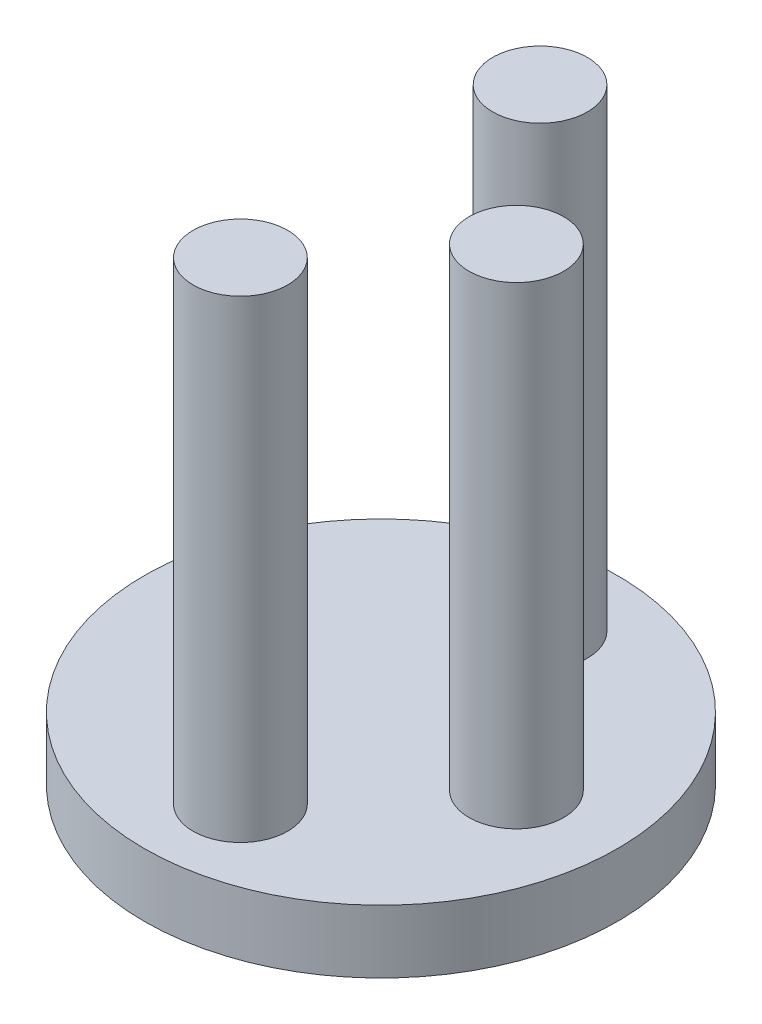
from build123d import *

# Parameters (mm, degrees)
SKETCH1_R           = 7.5
BOSS_EXTRUDE1_DEPTH = 2
SKETCH2_R           = 1.5
BOSS_EXTRUDE2_DEPTH = 15


with BuildPart() as part:
    # Sketch1 → Boss-Extrude1 (new body)
    with BuildSketch(Plane(origin=(0, 0, 0), x_dir=(1, 0, 0), z_dir=(0, 1, 0))):
        Circle(SKETCH1_R)
    extrude(amount=BOSS_EXTRUDE1_DEPTH)

    # Sketch2 → Boss-Extrude2 (add)
    with BuildSketch(Plane(origin=(0, 2, 0), x_dir=(1, 0, 0), z_dir=(0, 1, 0))):
        with Locations((0.294077072, -4.75)):
            Circle(SKETCH2_R)
        with Locations((0.294077072, 4.75)):
            Circle(SKETCH2_R)
        with Locations((4.294077072, 0)):
            Circle(SKETCH2_R)
    extrude(amount=BOSS_EXTRUDE2_DEPTH)


solid = part.part
